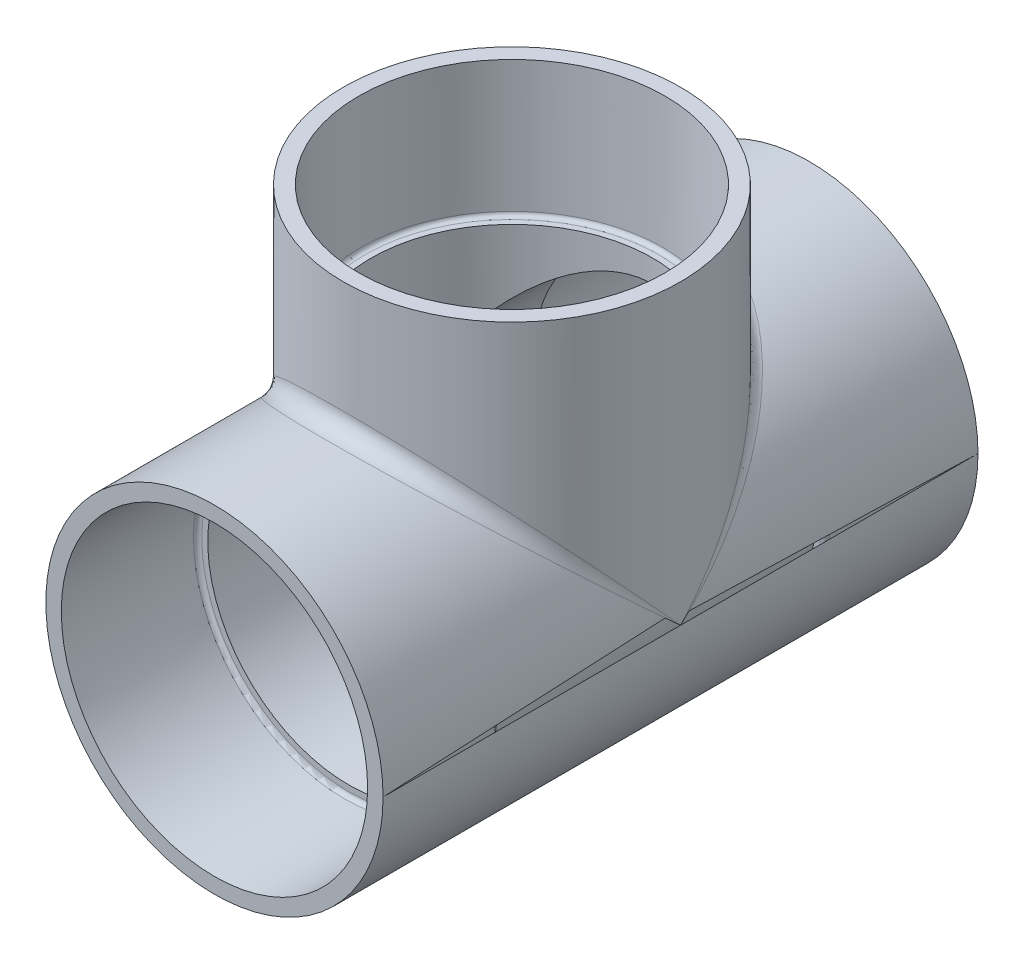
from build123d import *

# Parameters (mm, degrees)
BOSS_EXTRUDE1_REACH      = 178.609
BOSS_EXTRUDE1_END_RADIUS = 63.896875
SKETCH2_R                = 63.896875
CUT_EXTRUDE1_REACH       = 127.809
CUT_EXTRUDE1_END_RADIUS  = 53.34
SKETCH4_R                = 53.34
FILLET1_R                = 1.5875
FILLET2_R                = 6.35


with BuildPart() as part:
    # Sketch1 → Revolve1 (revolve)
    with BuildSketch(Plane(origin=(0, 0, 0), x_dir=(0, 0, -1), z_dir=(1, 0, 0)), mode=Mode.PRIVATE) as revolve1_sk:
        Polygon((-112.7125, 63.896875), (112.7125, 63.896875), (112.7125, 58.036717298), (61.9125, 57.15), (61.9125, 53.34), (-61.9125, 53.34), (-61.9125, 57.15), (-112.7125, 58.036717298), align=None)
    revolve(revolve1_sk.sketch.rotate(Axis((0, 0, 168.705111385), (0, 0, -1)), 90), axis=Axis((0, 0, 168.705111385), (0, 0, -1)))  # turned: the seam where the file's is

    # Boss-Extrude1: up to this cylinder (the profile starts outside it)
    boss_extrude1_end = Plane(origin=(0, 0, 0), z_dir=(0, 0, 1)) * Cylinder(BOSS_EXTRUDE1_END_RADIUS, 486.01175, mode=Mode.PRIVATE)
    # Sketch2 → Boss-Extrude1 (add, up to the surface)
    with BuildSketch(Plane(origin=(0, 112.7125, 0), x_dir=(1, 0, 0), z_dir=(0, 1, 0)), mode=Mode.PRIVATE) as boss_extrude1_sk1:
        with Locations(Location((0, 0, 0), (0, 0, 270))):  # turned: the seam where the file's is
            Circle(SKETCH2_R)
    boss_extrude1_tool1 = extrude(boss_extrude1_sk1.sketch, amount=-BOSS_EXTRUDE1_REACH, mode=Mode.PRIVATE) - boss_extrude1_end
    add(boss_extrude1_tool1.solids().sort_by_distance((0, 112.7125, 0))[0])

    # Sketch3 → Cut-Revolve1 (revolve, cut)
    with BuildSketch(Plane(origin=(0, 0, 0), x_dir=(0, 0, -1), z_dir=(1, 0, 0))):
        Polygon((-58.036717298, 112.7125), (-57.15, 61.9125), (0, 61.9125), (0, 112.7125), align=None)
    revolve(axis=Axis((0, 0, 0), (0, 1, 0)), mode=Mode.SUBTRACT)

    # Cut-Extrude1: up to this cylinder (the profile starts outside it)
    cut_extrude1_end = Plane(origin=(0, 0, 0), z_dir=(0, 0, 1)) * Cylinder(CUT_EXTRUDE1_END_RADIUS, 363.298, mode=Mode.PRIVATE)
    # Sketch4 → Cut-Extrude1 (cut, up to the surface)
    with BuildSketch(Plane(origin=(0, 61.9125, 0), x_dir=(1, 0, 0), z_dir=(0, 1, 0)), mode=Mode.PRIVATE) as cut_extrude1_sk1:
        with Locations(Location((0, 0, 0), (0, 0, 270))):  # turned: the seam where the file's is
            Circle(SKETCH4_R)
    cut_extrude1_tool1 = extrude(cut_extrude1_sk1.sketch, amount=-CUT_EXTRUDE1_REACH, mode=Mode.PRIVATE) - cut_extrude1_end
    add(cut_extrude1_tool1.solids().sort_by_distance((0, 61.9125, 0))[0], mode=Mode.SUBTRACT)

    # Fillet1
    fillet1_edges = [part.edges().sort_by_distance(p)[0] for p in [
        (0, 61.9125, -57.15),
        (-57.15, 0, 61.9125),
        (-57.15, 0, -61.9125),
    ]]
    fillet(fillet1_edges, radius=FILLET1_R)

    # Fillet2
    fillet2_edges = [part.edges().sort_by_distance(p)[0] for p in [
        (48.772230172, 41.280506281, 41.280506281),
        (-48.772230172, 41.280506281, -41.280506281),
    ]]
    fillet(fillet2_edges, radius=FILLET2_R)


solid = part.part
